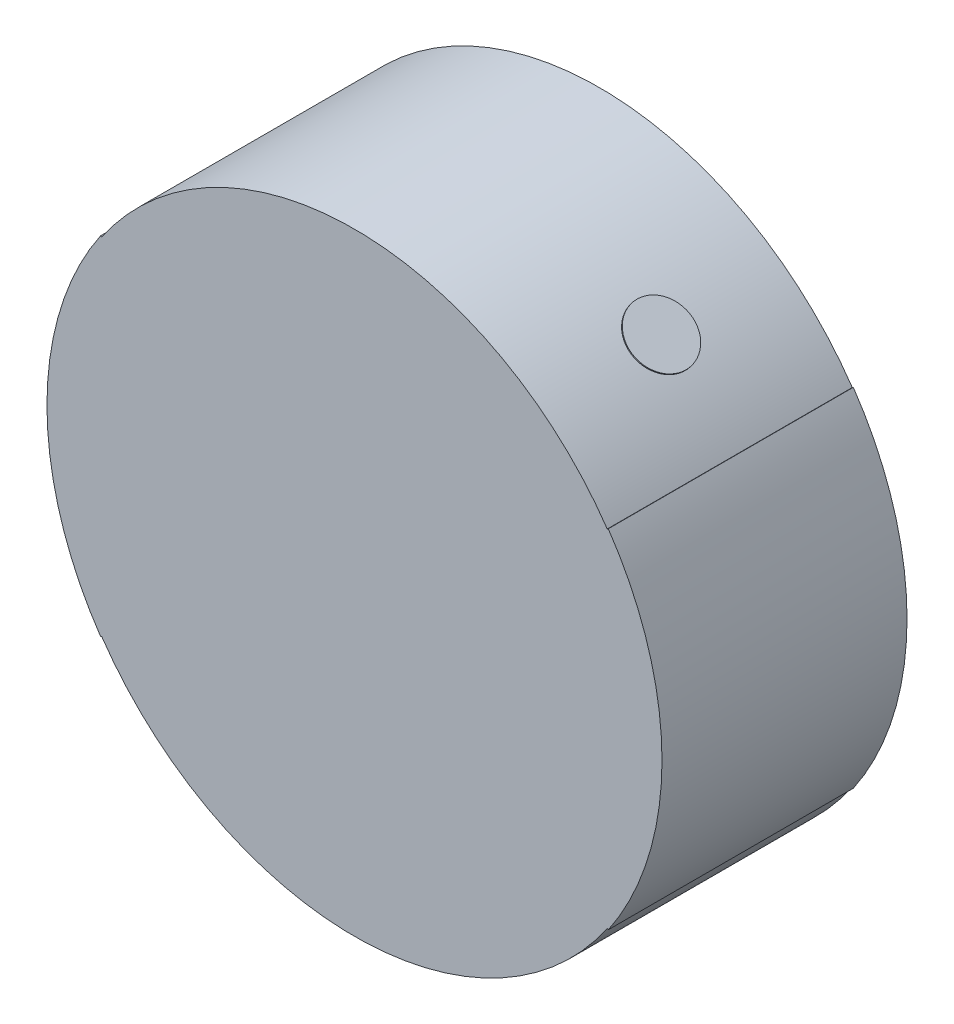
from build123d import *

# Parameters (mm, degrees)
SKETCH1_R           = 2.5
BOSS_EXTRUDE3_DEPTH = 1
BOSS_EXTRUDE4_DEPTH = 2
SKETCH12_4_R        = 0.25
BOSS_EXTRUDE5_DEPTH = 0.01


with BuildPart() as part:
    # Sketch1 → Boss-Extrude3 (new body, symmetric)
    with BuildSketch(Plane.XY):
        Circle(SKETCH1_R)
    extrude(amount=BOSS_EXTRUDE3_DEPTH, both=True)

    # Sketch2 → Boss-Extrude4 (add)
    with BuildSketch(Plane.XY.offset(1)):
        with BuildLine():
            Line((2.063339037, 1.411606183), (2.071592393, 1.417252608))
            ThreePointArc((2.071592393, 1.417252608), (2.51, 0), (2.071592393, -1.417252608))
            Line((2.071592393, -1.417252608), (2.063339037, -1.411606183))
            ThreePointArc((2.063339037, -1.411606183), (2.5, 0), (2.063339037, 1.411606183))
        make_face()
    boss_extrude4 = extrude(amount=-BOSS_EXTRUDE4_DEPTH)

    # Mirror1: Boss-Extrude4 across plane
    add(boss_extrude4.mirror(Plane(origin=(0, 0, 0), x_dir=(0, 0, 1), z_dir=(1, 0, 0))))


with BuildPart() as body_2:
    # Sketch12_4 → Boss-Extrude5 (new body)
    with BuildSketch(Plane(origin=(1.5, 2, 0), x_dir=(0.8, -0.6, 0), z_dir=(0.6, 0.8, 0))):
        with Locations(Location((0, 0, 0), (0, 0, 180))):  # turned: the seam where the file's is
            Circle(SKETCH12_4_R)
    extrude(amount=BOSS_EXTRUDE5_DEPTH)


solid = Compound([part.part, body_2.part])
